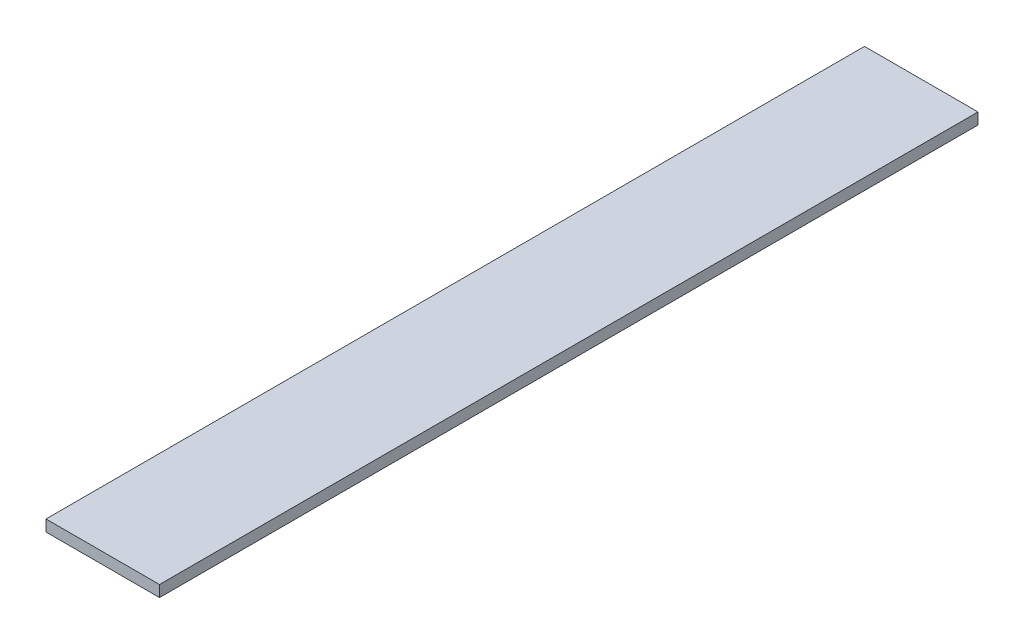
from build123d import *

# Parameters (mm, degrees)
SKETCH1_W           = 47.7
SKETCH1_H           = 4.7625
BOSS_EXTRUDE1_DEPTH = 343.95


with BuildPart() as part:
    # Sketch1 → Boss-Extrude1 (new body)
    with BuildSketch(Plane.XY):
        with Locations((23.85, 2.38125)):
            Rectangle(SKETCH1_W, SKETCH1_H)
    extrude(amount=BOSS_EXTRUDE1_DEPTH)


solid = part.part
